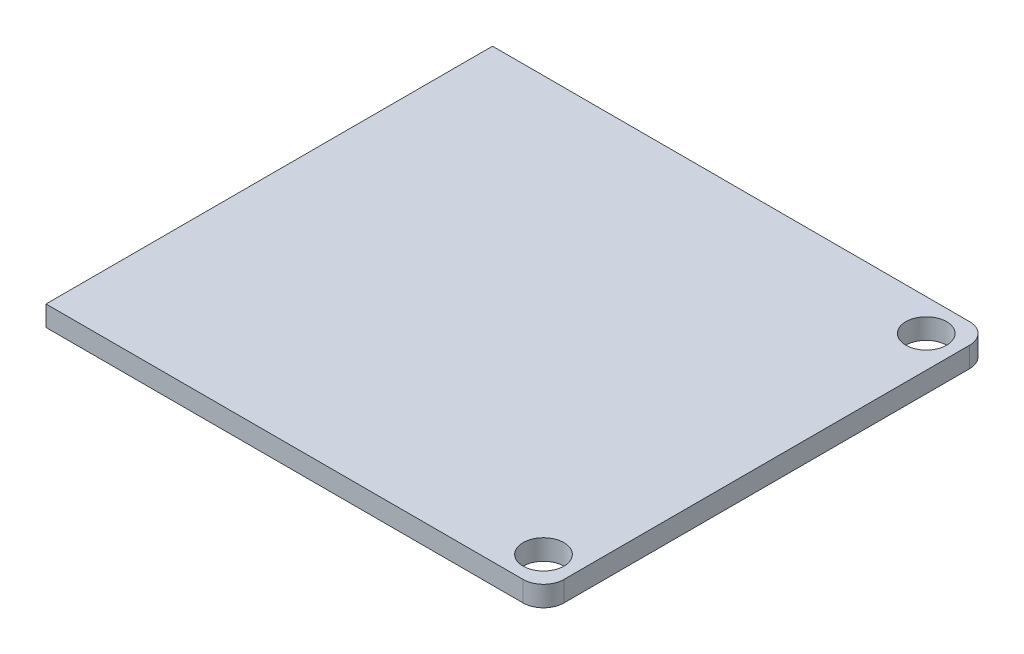
from build123d import *

# Parameters (mm, degrees)
SKETCH1_W           = 39
SKETCH1_H           = 35
BOSS_EXTRUDE1_DEPTH = 1.6
CUT_EXTRUDE1_REACH  = 3.6
SKETCH2_R           = 1.6
FILLET1_R           = 1.6


with BuildPart() as part:
    # Sketch1 → Boss-Extrude1 (new body)
    with BuildSketch(Plane(origin=(0, 0, 0), x_dir=(1, 0, 0), z_dir=(0, 1, 0))):
        Rectangle(SKETCH1_W, SKETCH1_H)
    extrude(amount=BOSS_EXTRUDE1_DEPTH)

    # Sketch2 → Cut-Extrude1 (cut, up to next)
    with BuildSketch(Plane(origin=(0, 1.6, 0), x_dir=(1, 0, 0), z_dir=(0, 1, 0)), mode=Mode.PRIVATE) as cut_extrude1_sk1:
        with Locations((17, 15)):
            Circle(SKETCH2_R)
    cut_extrude1_tool1 = extrude(cut_extrude1_sk1.sketch, amount=-CUT_EXTRUDE1_REACH, mode=Mode.PRIVATE) & part.part
    add(cut_extrude1_tool1.solids().sort_by_distance((17, 1.6, -15))[0], mode=Mode.SUBTRACT)
    # Sketch2 → Cut-Extrude1 (cut, up to next)
    with BuildSketch(Plane(origin=(0, 1.6, 0), x_dir=(1, 0, 0), z_dir=(0, 1, 0)), mode=Mode.PRIVATE) as cut_extrude1_sk2:
        with Locations((17, -15)):
            Circle(SKETCH2_R)
    cut_extrude1_tool2 = extrude(cut_extrude1_sk2.sketch, amount=-CUT_EXTRUDE1_REACH, mode=Mode.PRIVATE) & part.part
    add(cut_extrude1_tool2.solids().sort_by_distance((17, 1.6, 15))[0], mode=Mode.SUBTRACT)

    # Fillet1
    fillet1_edges = [part.edges().sort_by_distance(p)[0] for p in [
        (19.5, 0.8, 17.5),
        (19.5, 0.8, -17.5),
    ]]
    fillet(fillet1_edges, radius=FILLET1_R)


solid = part.part
